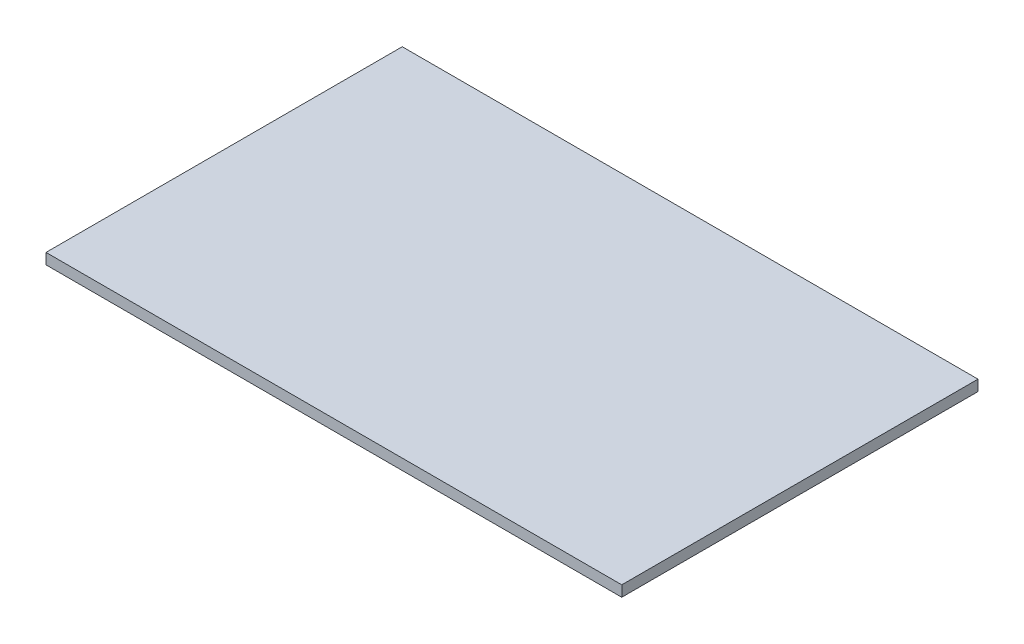
from build123d import *

# Parameters (mm, degrees)
SKETCH1_W           = 160
SKETCH1_H           = 99
BOSS_EXTRUDE1_DEPTH = 3


with BuildPart() as part:
    # Sketch1 → Boss-Extrude1 (new body)
    with BuildSketch(Plane(origin=(0, 0, 0), x_dir=(1, 0, 0), z_dir=(0, 1, 0))):
        with Locations((80, 49.5)):
            Rectangle(SKETCH1_W, SKETCH1_H)
    extrude(amount=BOSS_EXTRUDE1_DEPTH)


solid = part.part
